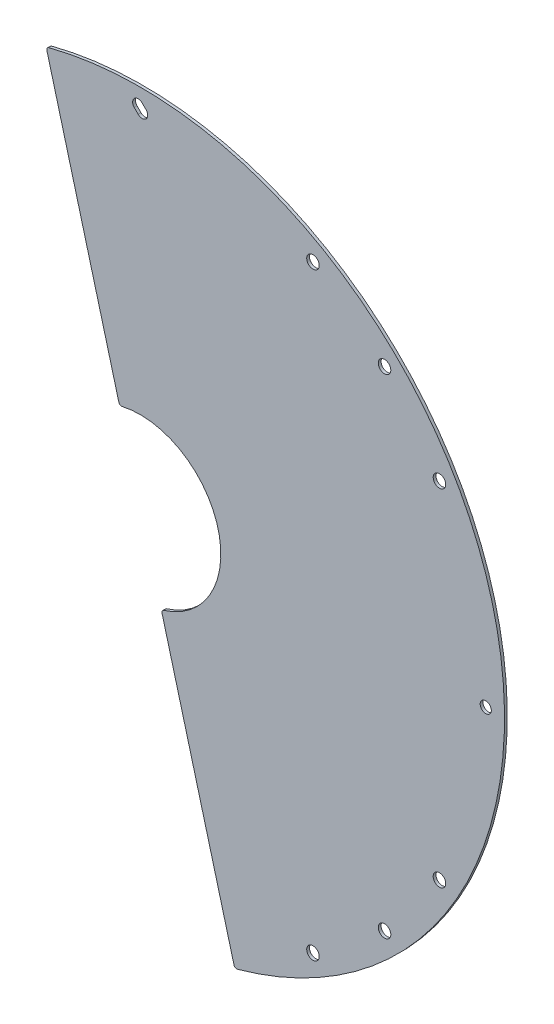
from build123d import *

# Parameters (mm, degrees)
SKETCH1_W                     = 1
SKETCH1_H                     = 102
REVOLVE_THIN1_ANGLE           = 15
REVOLVE_THIN1_OTHER_WAY_ANGLE = 165
F_4_5_4_5_DIAMETER_HOLE1_D    = 4.5
CIRPATTERN1_COUNT             = 12
F_4_0_4_DIAMETER_HOLE1_D      = 4
CIRPATTERN2_COUNT             = 4
F_4_5_4_5_DIAMETER_HOLE2_D    = 4.5
CIRPATTERN3_COUNT             = 2
CIRPATTERN3_ANGLE             = 90
CUT_EXTRUDE1_DEPTH            = 2
CUT_EXTRUDE2_DEPTH            = 2
FILLET1_R                     = 1


with BuildPart() as part:
    # Sketch1 → Revolve-Thin1 (revolve)
    with BuildSketch(Plane(origin=(0, 0, 0), x_dir=(0, 0, -1), z_dir=(1, 0, 0))):
        with Locations((-0.5, 80)):
            Rectangle(SKETCH1_W, SKETCH1_H)
    revolve(axis=Axis((0, 0, 0), (0, 0, 1)), revolution_arc=REVOLVE_THIN1_ANGLE)

    # Sketch1 → Revolve-Thin1 other way (revolve)
    with BuildSketch(Plane(origin=(0, 0, 0), x_dir=(0, 0, -1), z_dir=(1, 0, 0))):
        with Locations((-0.5, 80)):
            Rectangle(SKETCH1_W, SKETCH1_H)
    revolve(axis=Axis((0, 0, 0), (0, 0, -1)), revolution_arc=REVOLVE_THIN1_OTHER_WAY_ANGLE)

    # Ø4.5 (4.5) Diameter Hole1 (through all)
    with Locations(Plane.XY.offset(1)):
        with Locations((62.125, 107.60365642)):
            f_4_5_4_5_diameter_hole1 = Hole(F_4_5_4_5_DIAMETER_HOLE1_D / 2)

    # CirPattern1: Ø4.5 (4.5) Diameter Hole1 ×12 about axis, 8 skipped
    cirpattern1_axis = Axis((0, 0, -80.9), (0, 0, 1))
    add([f_4_5_4_5_diameter_hole1.rotate(cirpattern1_axis, i * 360 / CIRPATTERN1_COUNT) for i in range(1, CIRPATTERN1_COUNT) if i not in (1, 2, 3, 4, 5, 6, 7, 10)], mode=Mode.SUBTRACT)

    # Ø4.0 (4) Diameter Hole1 (through all)
    with Locations(Plane.XY.offset(1)):
        with Locations((124.25, 0)):
            f_4_0_4_diameter_hole1 = Hole(F_4_0_4_DIAMETER_HOLE1_D / 2)

    # CirPattern2: Ø4.0 (4) Diameter Hole1 ×4 about axis, 2 skipped
    cirpattern2_axis = Axis((0, 0, -80.9), (0, 0, 1))
    add([f_4_0_4_diameter_hole1.rotate(cirpattern2_axis, i * 360 / CIRPATTERN2_COUNT) for i in range(1, CIRPATTERN2_COUNT) if i not in (2, 3)], mode=Mode.SUBTRACT)

    # Ø4.5 (4.5) Diameter Hole2 (through all)
    with Locations(Plane.XY.offset(1)):
        with Locations((87.858017562, 87.858017562)):
            f_4_5_4_5_diameter_hole2 = Hole(F_4_5_4_5_DIAMETER_HOLE2_D / 2)

    # CirPattern3: Ø4.5 (4.5) Diameter Hole2 ×2 about axis
    cirpattern3_axis = Axis((0, 0, -80.9), (0, 0, -1))
    for i in range(1, CIRPATTERN3_COUNT):
        add(f_4_5_4_5_diameter_hole2.rotate(cirpattern3_axis, i * CIRPATTERN3_ANGLE / (CIRPATTERN3_COUNT - 1)), mode=Mode.SUBTRACT)

    # Sketch12 → Cut-Extrude1 (cut, through all)
    with BuildSketch(Plane.XY.offset(1)):
        with BuildLine():
            Line((0.707106781, 126.371320344), (2.121320344, 124.957106781))
            ThreePointArc((2.121320344, 124.957106781), (2.121320344, 122.128679656), (-0.707106781, 122.128679656))
            Line((-0.707106781, 122.128679656), (-2.121320344, 123.542893219))
            ThreePointArc((-2.121320344, 123.542893219), (-2.121320344, 126.371320344), (0.707106781, 126.371320344))
        make_face()
    extrude(amount=-CUT_EXTRUDE1_DEPTH, mode=Mode.SUBTRACT)

    # Sketch13 → Cut-Extrude2 (cut, through all)
    with BuildSketch(Plane.XY.offset(1)):
        Polygon((-33.905294908, 126.536283244), (33.905294908, -126.536283244), (34.001887491, -126.510401339), (-33.808702326, 126.562165148), align=None)
    extrude(amount=-CUT_EXTRUDE2_DEPTH, mode=Mode.SUBTRACT)

    # Fillet1
    fillet1_edges = [part.edges().sort_by_distance(p)[0] for p in [
        (-7.409115101, 28.037564327, 0.5),
        (7.602300266, -27.985800518, 0.5),
        (34.001877612, -126.510364472, 0.5),
        (-33.808692447, 126.562128281, 0.5),
    ]]
    fillet(fillet1_edges, radius=FILLET1_R)


solid = part.part
